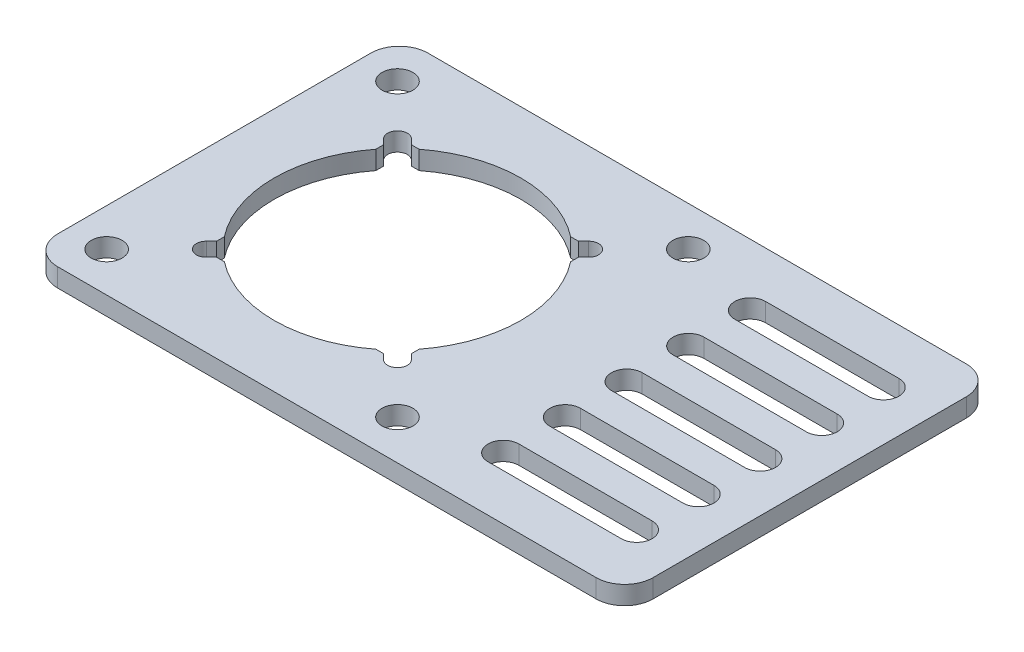
from build123d import *

# Parameters (mm, degrees)
SKETCH2_R           = 2.5
BOSS_EXTRUDE1_DEPTH = 3


with BuildPart() as part:
    # Sketch2 → Boss-Extrude1 (new body)
    with BuildSketch(Plane(origin=(0, 0, 0), x_dir=(1, 0, 0), z_dir=(0, 1, 0))):
        with BuildLine():
            Line((-43.63, 60), (43.63, 60))
            ThreePointArc((43.63, 60), (46.896833329, 58.646833329), (48.25, 55.38))
            Line((48.25, 55.38), (48.25, 4.62))
            ThreePointArc((48.25, 4.62), (46.896833329, 1.353166671), (43.63, 0))
            Line((43.63, 0), (-43.63, 0))
            ThreePointArc((-43.63, 0), (-46.896833329, 1.353166671), (-48.25, 4.62))
            Line((-48.25, 4.62), (-48.25, 55.38))
            ThreePointArc((-48.25, 55.38), (-46.896833329, 58.646833329), (-43.63, 60))
        make_face()
        with Locations((-42.13, 6.43)):
            Circle(SKETCH2_R, mode=Mode.SUBTRACT)
        with Locations((-42.13, 53.57)):
            Circle(SKETCH2_R, mode=Mode.SUBTRACT)
        with Locations((5.01, 53.57)):
            Circle(SKETCH2_R, mode=Mode.SUBTRACT)
        with Locations((5.01, 6.43)):
            Circle(SKETCH2_R, mode=Mode.SUBTRACT)
        with BuildLine():
            Line((18.61, 52.5), (40.21, 52.5))
            ThreePointArc((40.21, 52.5), (42.71, 50), (40.21, 47.5))
            Line((40.21, 47.5), (18.61, 47.5))
            ThreePointArc((18.61, 47.5), (16.11, 50), (18.61, 52.5))
        make_face(mode=Mode.SUBTRACT)
        with BuildLine():
            Line((18.61, 7.5), (40.21, 7.5))
            ThreePointArc((40.21, 7.5), (42.71, 10), (40.21, 12.5))
            Line((40.21, 12.5), (18.61, 12.5))
            ThreePointArc((18.61, 12.5), (16.11, 10), (18.61, 7.5))
        make_face(mode=Mode.SUBTRACT)
        with BuildLine():
            Line((18.61, 32.5), (40.21, 32.5))
            ThreePointArc((40.21, 32.5), (42.71, 30), (40.21, 27.5))
            Line((40.21, 27.5), (18.61, 27.5))
            ThreePointArc((18.61, 27.5), (16.11, 30), (18.61, 32.5))
        make_face(mode=Mode.SUBTRACT)
        with BuildLine():
            Line((18.61, 42.5), (40.21, 42.5))
            ThreePointArc((40.21, 42.5), (42.71, 40), (40.21, 37.5))
            Line((40.21, 37.5), (18.61, 37.5))
            ThreePointArc((18.61, 37.5), (16.11, 40), (18.61, 42.5))
        make_face(mode=Mode.SUBTRACT)
        with BuildLine():
            Line((18.61, 17.5), (40.21, 17.5))
            ThreePointArc((40.21, 17.5), (42.71, 20), (40.21, 22.5))
            Line((40.21, 22.5), (18.61, 22.5))
            ThreePointArc((18.61, 22.5), (16.11, 20), (18.61, 17.5))
        make_face(mode=Mode.SUBTRACT)
        with BuildLine():
            Line((-5.025372417, 45.790298215), (-4.191590206, 46.624080426))
            ThreePointArc((-4.191590206, 46.624080426), (-1.935919574, 46.624080426), (-1.935919574, 44.368409794))
            Line((-1.935919574, 44.368409794), (-2.769701785, 43.534627583))
            Line((-2.769701785, 43.534627583), (-2.769701785, 42.274627583))
            ThreePointArc((-2.769701785, 42.274627583), (1.44, 30), (-2.769701785, 17.725372417))
            Line((-2.769701785, 17.725372417), (-2.769701785, 16.465372417))
            Line((-2.769701785, 16.465372417), (-1.935919574, 15.631590206))
            ThreePointArc((-1.935919574, 15.631590206), (-1.935919574, 13.375919574), (-4.191590206, 13.375919574))
            Line((-4.191590206, 13.375919574), (-5.025372417, 14.209701785))
            Line((-5.025372417, 14.209701785), (-6.285372417, 14.209701785))
            ThreePointArc((-6.285372417, 14.209701785), (-18.56, 10), (-30.834627583, 14.209701785))
            Line((-30.834627583, 14.209701785), (-32.094627583, 14.209701785))
            Line((-32.094627583, 14.209701785), (-32.928409794, 13.375919574))
            ThreePointArc((-32.928409794, 13.375919574), (-35.184080426, 13.375919574), (-35.184080426, 15.631590206))
            Line((-35.184080426, 15.631590206), (-34.350298215, 16.465372417))
            Line((-34.350298215, 16.465372417), (-34.350298215, 17.725372417))
            ThreePointArc((-34.350298215, 17.725372417), (-38.56, 30), (-34.350298215, 42.274627583))
            Line((-34.350298215, 42.274627583), (-34.350298215, 43.534627583))
            Line((-34.350298215, 43.534627583), (-35.184080426, 44.368409794))
            ThreePointArc((-35.184080426, 44.368409794), (-35.184080426, 46.624080426), (-32.928409794, 46.624080426))
            Line((-32.928409794, 46.624080426), (-32.094627583, 45.790298215))
            Line((-32.094627583, 45.790298215), (-30.834627583, 45.790298215))
            ThreePointArc((-30.834627583, 45.790298215), (-18.56, 50), (-6.285372417, 45.790298215))
            Line((-6.285372417, 45.790298215), (-5.025372417, 45.790298215))
        make_face(mode=Mode.SUBTRACT)
    extrude(amount=BOSS_EXTRUDE1_DEPTH)


solid = part.part
